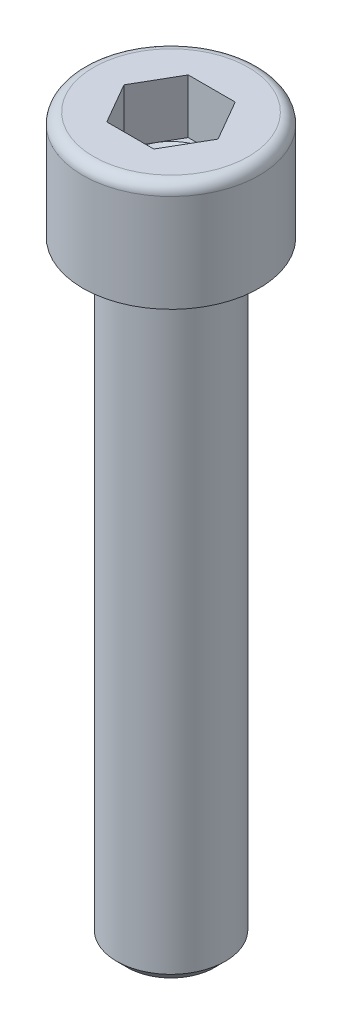
from build123d import *

# Parameters (mm, degrees)
ESQUISSE2_R             = 4
BASE_EXTRUSION_DEPTH    = 45
CHANFREIN1_SIZE         = 0.8
ENL_V_MAT_EXTRU_1_DEPTH = 4


with BuildPart() as part:
    # Esquisse2 → Base-Extrusion (new body)
    with BuildSketch(Plane(origin=(0, 0, 0), x_dir=(1, 0, 0), z_dir=(0, 1, 0))):
        with Locations(Location((0, 0, 0), (0, 0, 270))):  # turned: the seam where the file's is
            Circle(ESQUISSE2_R)
    extrude(amount=-BASE_EXTRUSION_DEPTH)

    # Chanfrein1
    chanfrein1_edges = [part.edges().sort_by_distance(p)[0] for p in [
        (0, -45, -4),
    ]]
    chamfer(chanfrein1_edges, length=CHANFREIN1_SIZE)

    # Esquisse5 → Boss.-Révol.1 (revolve)
    with BuildSketch(Plane.XY, mode=Mode.PRIVATE) as boss_r_vol_1_sk:
        with BuildLine():
            Line((3, 8), (3, 4))
            Line((3, 4), (0, 2.267949192))
            Line((0, 2.267949192), (0, 0))
            Line((0, 0), (6.5, 0))
            Line((6.5, 0), (6.5, 7.2))
            ThreePointArc((6.5, 7.2), (6.265685425, 7.765685425), (5.7, 8))
            Line((5.7, 8), (3, 8))
        make_face()
    revolve(boss_r_vol_1_sk.sketch.rotate(Axis((0, 8, 0), (0, -1, 0)), 90), axis=Axis((0, 8, 0), (0, -1, 0)))  # turned: the seam where the file's is

    # Esquisse7 → Enlèv. mat.-Extru.1 (cut)
    with BuildSketch(Plane(origin=(0, 8, 0), x_dir=(-1, 0, 0), z_dir=(0, 1, 0))):
        Polygon((1.732050808, 3), (-1.732050808, 3), (-3.464101615, 0), (-1.732050808, -3), (1.732050808, -3), (3.464101615, 0), align=None)
    extrude(amount=-ENL_V_MAT_EXTRU_1_DEPTH, mode=Mode.SUBTRACT)


solid = part.part
